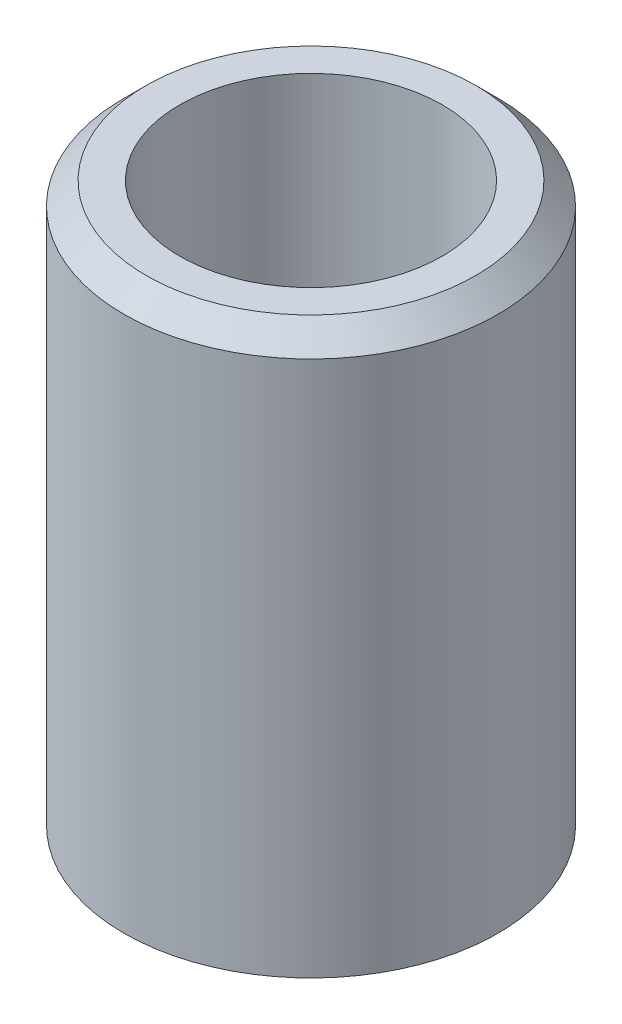
from build123d import *

# Parameters (mm, degrees)
SKETCH2_W     = 2.5
SKETCH2_H     = 25
CHAMFER1_SIZE = 1


with BuildPart() as part:
    # Sketch2 → Revolve1 (revolve)
    with BuildSketch(Plane.XY):
        with Locations((-7.125, 12.5)):
            Rectangle(SKETCH2_W, SKETCH2_H)
    revolve(axis=Axis((0, 0, 0), (0, 1, 0)))

    # Chamfer1
    chamfer1_edges = [part.edges().sort_by_distance(p)[0] for p in [
        (8.375, 25, 0),
    ]]
    chamfer(chamfer1_edges, length=CHAMFER1_SIZE)


solid = part.part
